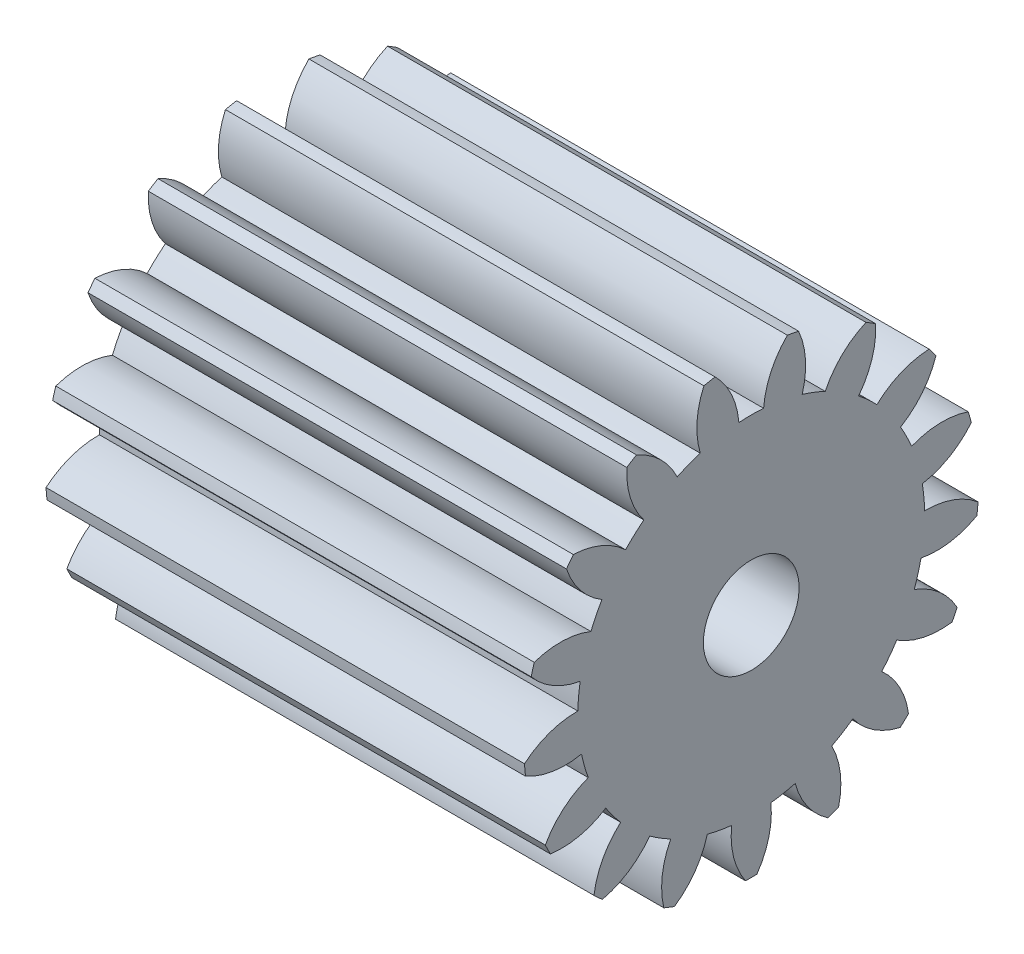
from build123d import *

# Parameters (mm, degrees)
BASPROSKE_W     = 10
BASPROSKE_H     = 4.75
TOOTHCUT_DEPTH  = 13.046783803
TEETHCUTS_COUNT = 17
TEETHCUTS_ANGLE = 338.823529412
BORSKE_R        = 1
BORE_DEPTH      = 50.0000508


with BuildPart() as part:
    # BasProSke → Base-Revolve (revolve)
    with BuildSketch(Plane(origin=(0, 0, 0), x_dir=(1, 0, 0), z_dir=(0, 1, 0)), mode=Mode.PRIVATE) as base_revolve_sk:
        with Locations((5, 2.375)):
            Rectangle(BASPROSKE_W, BASPROSKE_H)
    revolve(base_revolve_sk.sketch.rotate(Axis((-10, 0, 0), (1, 0, 0)), 180), axis=Axis((-10, 0, 0), (1, 0, 0)))

    # TooCutSke → ToothCut (cut, through all)
    with BuildSketch(Plane(origin=(0, 0, 0), x_dir=(0, 0, -1), z_dir=(1, 0, 0))):
        with BuildLine():
            ThreePointArc((0.258391906, 3.614776566), (0, 3.624), (-0.258391906, 3.614776566))
            ThreePointArc((-0.258391906, 3.614776566), (-0.416942797, 4.211135742), (-0.777923303, 4.711611242))
            ThreePointArc((-0.777923303, 4.711611242), (0, 4.7754), (0.777923303, 4.711611242))
            ThreePointArc((0.777923303, 4.711611242), (0.416942797, 4.211135742), (0.258391906, 3.614776566))
        make_face()
    toothcut = extrude(amount=TOOTHCUT_DEPTH, mode=Mode.SUBTRACT)

    # TeethCuts: ToothCut ×17 about axis
    teethcuts_axis = Axis((-10, 0, 0), (1, 0, 0))
    for i in range(1, TEETHCUTS_COUNT):
        add(toothcut.rotate(teethcuts_axis, i * TEETHCUTS_ANGLE / (TEETHCUTS_COUNT - 1)), mode=Mode.SUBTRACT)

    # BorSke → Bore (cut, symmetric)
    with BuildSketch(Plane(origin=(0, 0, 0), x_dir=(0, 0, -1), z_dir=(1, 0, 0))):
        with Locations(Location((0, 0, 0), (0, 0, 180))):
            Circle(BORSKE_R)
    extrude(amount=BORE_DEPTH, both=True, mode=Mode.SUBTRACT)


solid = part.part
